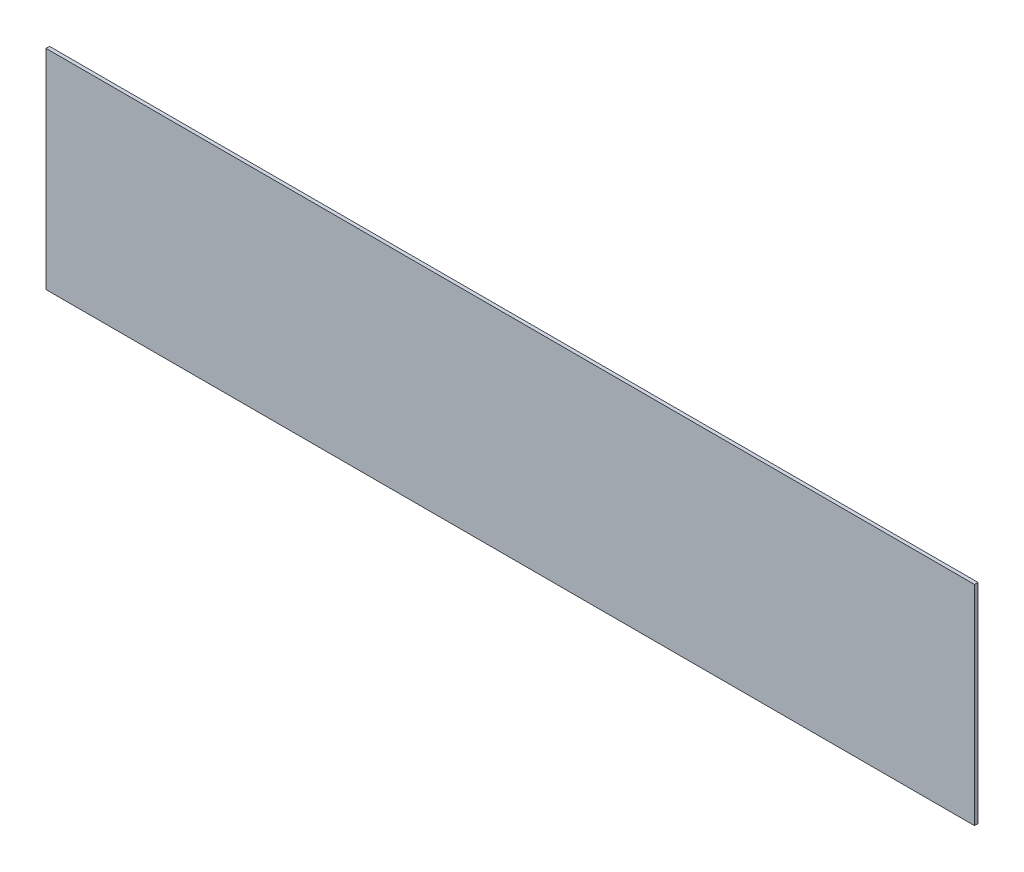
from build123d import *

# Parameters (mm, degrees)
SKETCH_1_W      = 400
SKETCH_1_H      = 90
EXTRUDE_1_DEPTH = 1.5


with BuildPart() as part:
    # 草圖1 → 填料-伸長1 (new body)
    with BuildSketch(Plane.XY):
        with Locations((-69.032324472, -30.219683656)):
            Rectangle(SKETCH_1_W, SKETCH_1_H)
    extrude(amount=EXTRUDE_1_DEPTH)


solid = part.part
